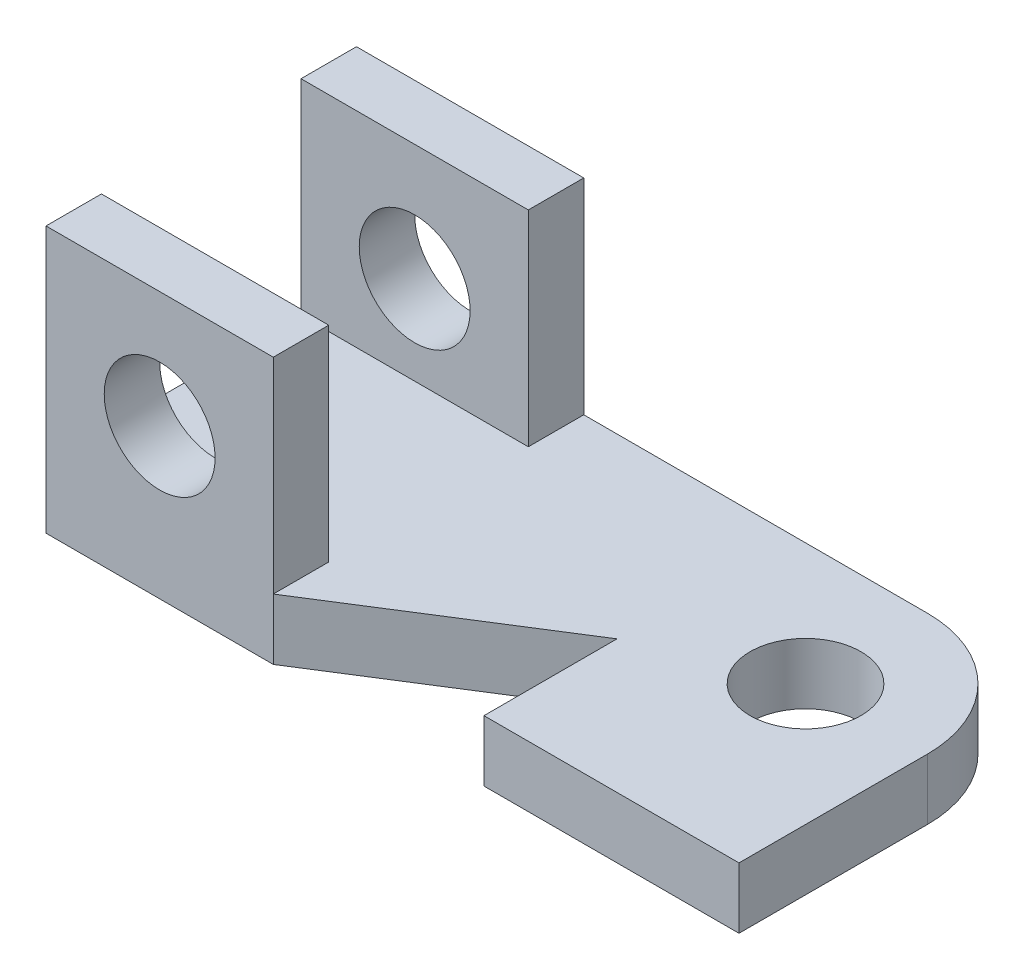
from build123d import *

# Parameters (mm, degrees)
SKETCH2_R               = 10
BOSS_EXTRUDE1_DEPTH     = 11
SKETCH5_W               = 41
SKETCH5_H               = 10
BOSS_EXTRUDE3_DEPTH     = 37
SKETCH6_R               = 10
CUT_EXTRUDE1_DEPTH      = 1
CUT_EXTRUDE1_DEPTH_BACK = 57


with BuildPart() as part:
    # Sketch2 → Boss-Extrude1 (new body)
    with BuildSketch(Plane(origin=(0, 0, 0), x_dir=(1, 0, 0), z_dir=(0, 1, 0))):
        with BuildLine():
            Line((-46, 0), (-46, 24))
            Line((-46, 24), (-84, 0))
            Line((-84, 0), (-125, 0))
            Line((-125, 0), (-125, 56))
            Line((-125, 56), (-22, 56))
            ThreePointArc((-22, 56), (-6.443650814, 49.556349186), (0, 34))
            Line((0, 34), (0, 0))
            Line((0, 0), (-46, 0))
        make_face()
        with Locations((-22, 34)):
            Circle(SKETCH2_R, mode=Mode.SUBTRACT)
    extrude(amount=BOSS_EXTRUDE1_DEPTH)

    # Sketch5 → Boss-Extrude3 (add)
    with BuildSketch(Plane(origin=(0, 11, 0), x_dir=(1, 0, 0), z_dir=(0, 1, 0))):
        with Locations((-104.5, 51)):
            Rectangle(SKETCH5_W, SKETCH5_H)
        with Locations((-104.5, 5)):
            Rectangle(SKETCH5_W, SKETCH5_H)
    extrude(amount=BOSS_EXTRUDE3_DEPTH)

    # Sketch6 → Cut-Extrude1 (cut, two sides)
    with BuildSketch(Plane.XY) as cut_extrude1_sk:
        with Locations((-104.5, 27)):
            Circle(SKETCH6_R)
    extrude(amount=CUT_EXTRUDE1_DEPTH, mode=Mode.SUBTRACT)
    extrude(cut_extrude1_sk.sketch, amount=-CUT_EXTRUDE1_DEPTH_BACK, mode=Mode.SUBTRACT)


solid = part.part
